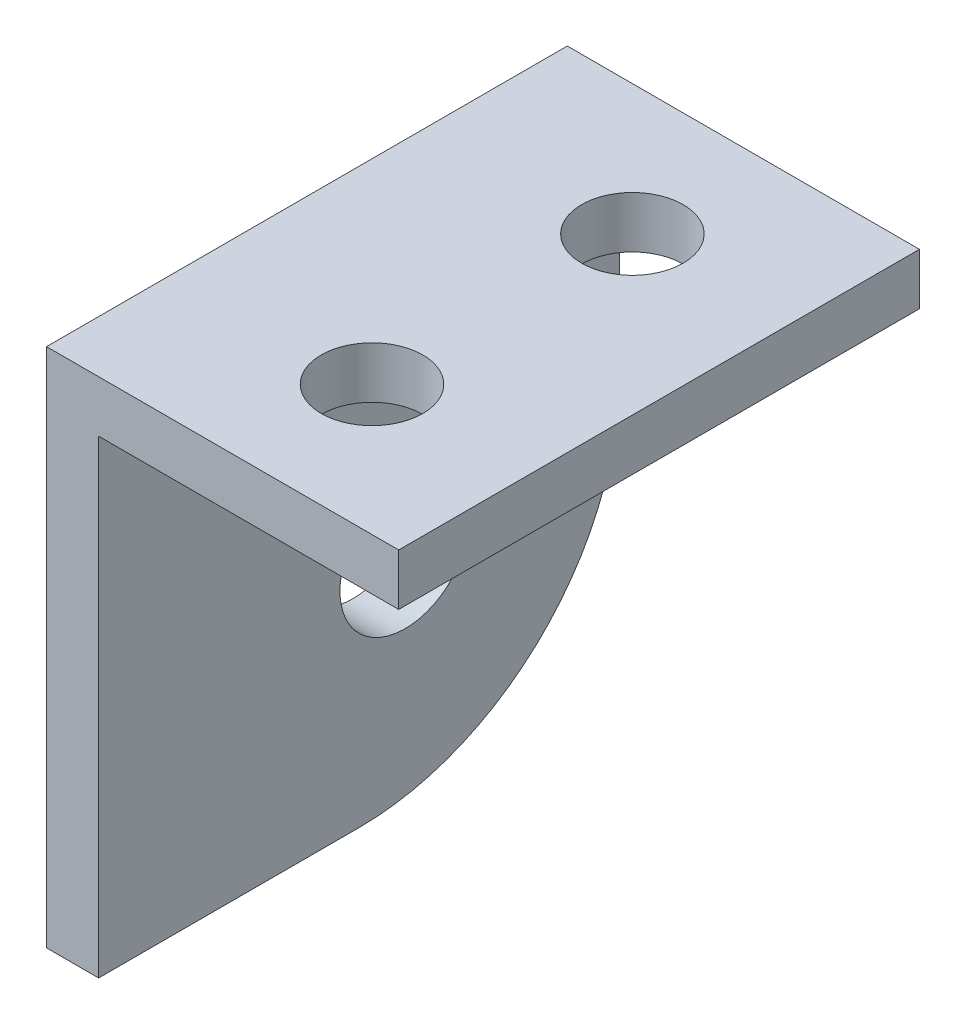
from build123d import *

# Parameters (mm, degrees)
BOSS_EXTRUDE1_DEPTH = 25.4
FILLET1_R           = 12.7
SKETCH2_R           = 3.175
CUT_EXTRUDE1_DEPTH  = 3.54
SKETCH3_R           = 2.4765
CUT_EXTRUDE2_DEPTH  = 3.512939161


with BuildPart() as part:
    # Sketch1 → Boss-Extrude1 (new body)
    with BuildSketch(Plane.XY):
        Polygon((-12.7, -12.7), (-12.7, 12.7), (4.47675, 12.7), (4.47675, 10.187060839), (-10.16, 10.187060839), (-10.16, -12.7), align=None)
    extrude(amount=BOSS_EXTRUDE1_DEPTH)

    # Fillet1
    fillet1_edges = [part.edges().sort_by_distance(p)[0] for p in [
        (-11.43, -12.7, 0),
    ]]
    fillet(fillet1_edges, radius=FILLET1_R)

    # Sketch2 → Cut-Extrude1 (cut, through all)
    with BuildSketch(Plane(origin=(-10.16, 0, 0), x_dir=(0, 0, -1), z_dir=(1, 0, 0))):
        with Locations((-10.45493597, -2.24506403)):
            Circle(SKETCH2_R)
    extrude(amount=-CUT_EXTRUDE1_DEPTH, mode=Mode.SUBTRACT)

    # Sketch3 → Cut-Extrude2 (cut, through all)
    with BuildSketch(Plane.XZ.offset(-10.187060839)):
        with Locations((-3.175, 19.05)):
            Circle(SKETCH3_R)
        with Locations((-3.175, 6.35)):
            Circle(SKETCH3_R)
    extrude(amount=-CUT_EXTRUDE2_DEPTH, mode=Mode.SUBTRACT)


solid = part.part
